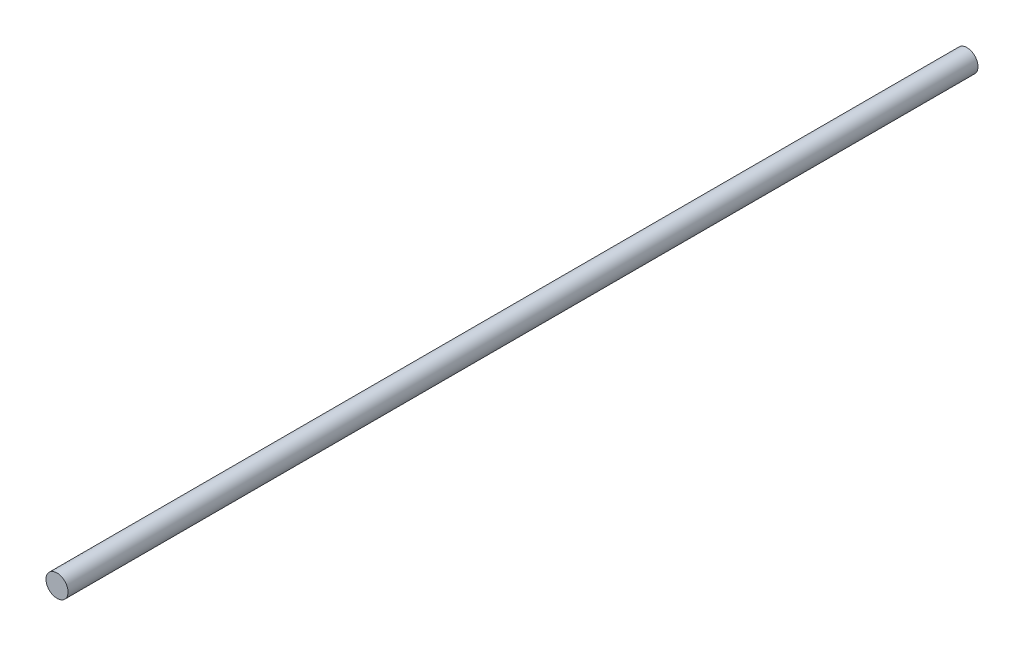
from build123d import *

# Parameters (mm, degrees)
SKETCH1_R           = 4
BOSS_EXTRUDE1_DEPTH = 330


with BuildPart() as part:
    # Sketch1 → Boss-Extrude1 (new body)
    with BuildSketch(Plane.XY):
        Circle(SKETCH1_R)
    extrude(amount=BOSS_EXTRUDE1_DEPTH)


solid = part.part
